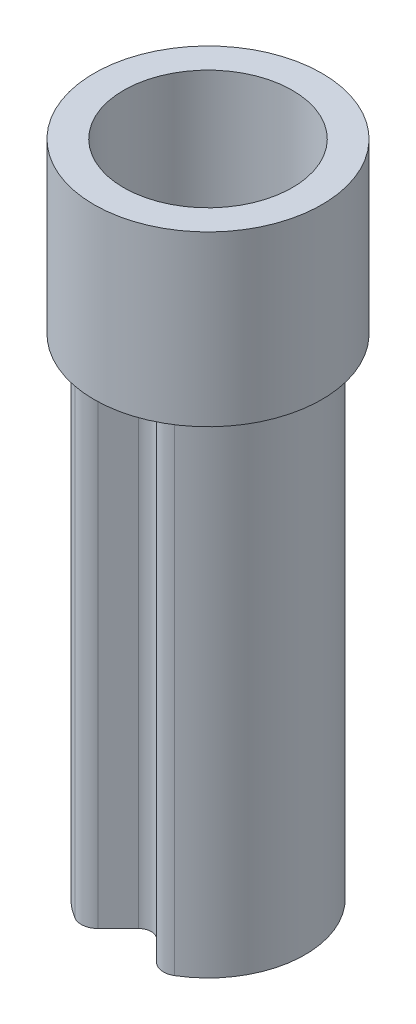
from build123d import *

# Parameters (mm, degrees)
BOSS_EXTRUDE1_DEPTH = 5.8
FILLET1_R           = 0.05
FILLET2_R           = 0.2
SKETCH2_R           = 1.35
SKETCH2_R_2         = 1
BOSS_EXTRUDE2_DEPTH = 2


with BuildPart() as part:
    # Sketch1 → Boss-Extrude1 (new body)
    with BuildSketch(Plane(origin=(0, 0, 0), x_dir=(1, 0, 0), z_dir=(0, 1, 0))):
        with BuildLine():
            Line((-0.448807004, -1.058807004), (-0.106066017, -0.716066017))
            ThreePointArc((-0.106066017, -0.716066017), (0, -0.672132034), (0.106066017, -0.716066017))
            Line((0.106066017, -0.716066017), (0.448807004, -1.058807004))
            ThreePointArc((0.448807004, -1.058807004), (0, 1.15), (-0.448807004, -1.058807004))
        make_face()
        with BuildLine():
            Line((-0.479612457, -0.877480422), (-0.212132034, -0.61))
            ThreePointArc((-0.212132034, -0.61), (0, -0.522132034), (0.212132034, -0.61))
            Line((0.212132034, -0.61), (0.479612457, -0.877480422))
            ThreePointArc((0.479612457, -0.877480422), (0, 1), (-0.479612457, -0.877480422))
        make_face(mode=Mode.SUBTRACT)
    extrude(amount=BOSS_EXTRUDE1_DEPTH)

    # Fillet1
    fillet1_edges = [part.edges().sort_by_distance(p)[0] for p in [
        (0.479612457, 2.9, 0.877480422),
        (-0.479612457, 2.9, 0.877480422),
    ]]
    fillet(fillet1_edges, radius=FILLET1_R)

    # Fillet2
    fillet2_edges = [part.edges().sort_by_distance(p)[0] for p in [
        (-0.448807004, 2.9, 1.058807004),
        (0.448807004, 2.9, 1.058807004),
    ]]
    fillet(fillet2_edges, radius=FILLET2_R)

    # Sketch2 → Boss-Extrude2 (add)
    with BuildSketch(Plane(origin=(0, 5.8, 0), x_dir=(1, 0, 0), z_dir=(0, 1, 0))):
        Circle(SKETCH2_R)
        Circle(SKETCH2_R_2, mode=Mode.SUBTRACT)
    extrude(amount=BOSS_EXTRUDE2_DEPTH)


solid = part.part
